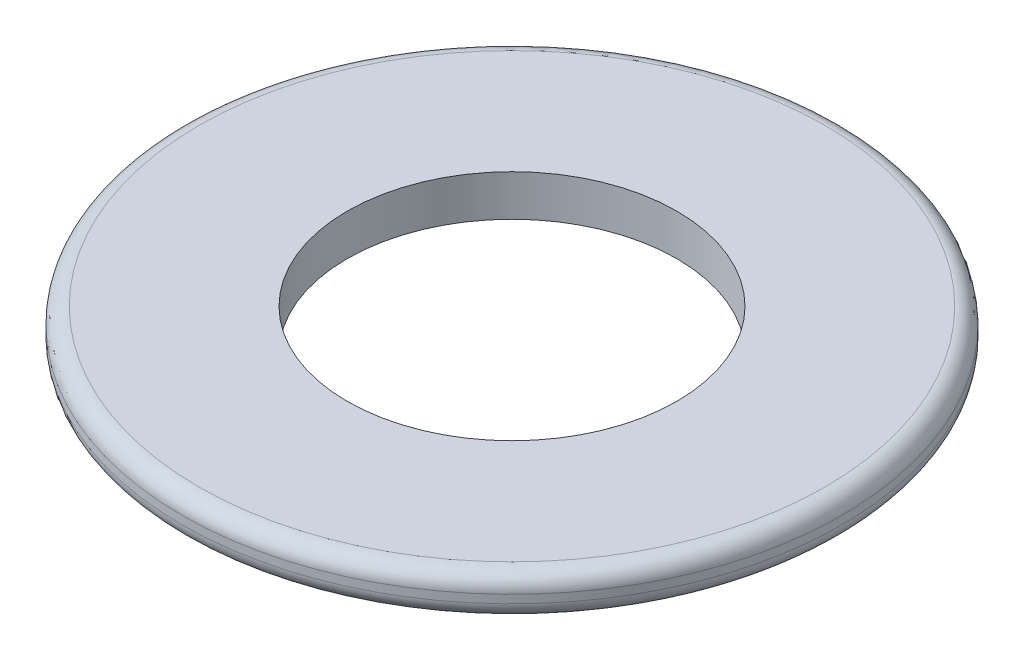
from build123d import *

# Parameters (mm, degrees)
SKETCH1_R           = 4
SKETCH1_R_2         = 2
BOSS_EXTRUDE1_DEPTH = 0.5
FILLET1_R           = 0.2
FILLET2_R           = 0.2


with BuildPart() as part:
    # Sketch1 → Boss-Extrude1 (new body)
    with BuildSketch(Plane(origin=(0, 0, 0), x_dir=(1, 0, 0), z_dir=(0, 1, 0))):
        Circle(SKETCH1_R)
        Circle(SKETCH1_R_2, mode=Mode.SUBTRACT)
    extrude(amount=BOSS_EXTRUDE1_DEPTH)

    # Fillet1
    fillet1_edges = [part.edges().sort_by_distance(p)[0] for p in [
        (-4, 0.5, 0),
    ]]
    fillet(fillet1_edges, radius=FILLET1_R)

    # Fillet2
    fillet2_edges = [part.edges().sort_by_distance(p)[0] for p in [
        (-4, 0, 0),
    ]]
    fillet(fillet2_edges, radius=FILLET2_R)


solid = part.part
